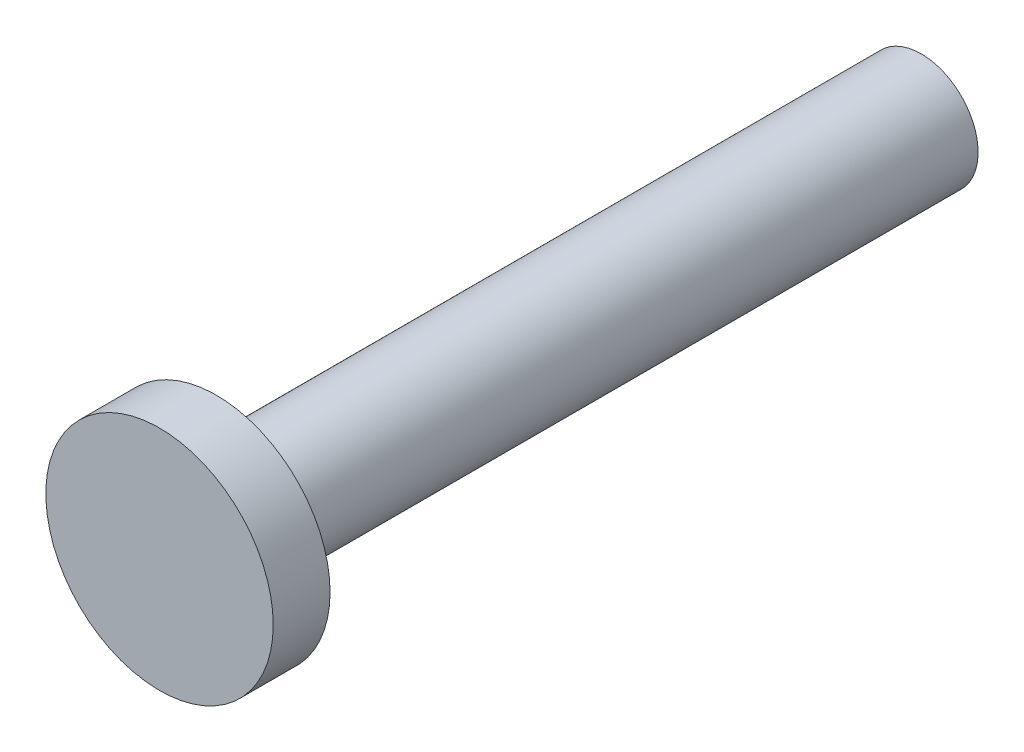
from build123d import *

# Parameters (mm, degrees)
SKETCH1_R           = 2.54
BOSS_EXTRUDE1_DEPTH = 1.27
SKETCH2_R           = 1.27
BOSS_EXTRUDE2_DEPTH = 15.748


with BuildPart() as part:
    # Sketch1 → Boss-Extrude1 (new body)
    with BuildSketch(Plane.XY):
        Circle(SKETCH1_R)
    extrude(amount=BOSS_EXTRUDE1_DEPTH)

    # Sketch2 → Boss-Extrude2 (add)
    with BuildSketch(Plane(origin=(0, 0, 0), x_dir=(-1, 0, 0), z_dir=(0, 0, -1))):
        Circle(SKETCH2_R)
    extrude(amount=BOSS_EXTRUDE2_DEPTH)


solid = part.part
